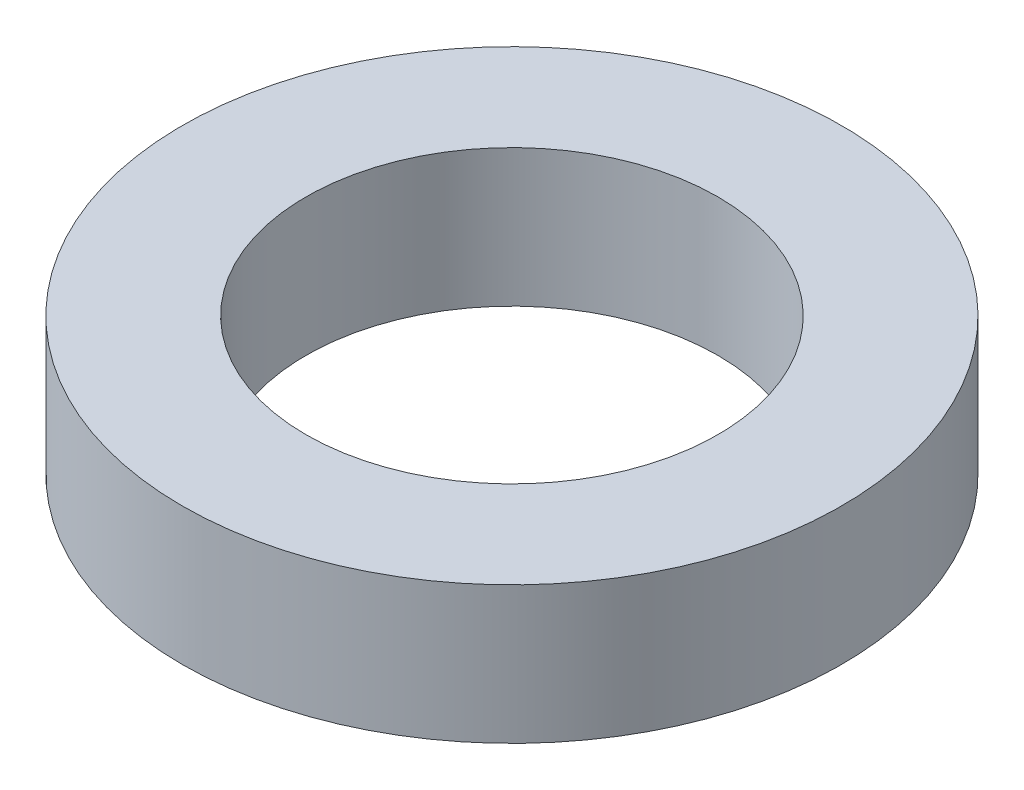
from build123d import *

# Parameters (mm, degrees)
SKETCH1_R           = 12.000000003
SKETCH1_R_2         = 7.499999986
BOSS_EXTRUDE1_DEPTH = 2.499999953


with BuildPart() as part:
    # Sketch1 → Boss-Extrude1 (new body, symmetric)
    with BuildSketch(Plane(origin=(0, 0, 0), x_dir=(1, 0, 0), z_dir=(0, 1, 0))):
        Circle(SKETCH1_R)
        Circle(SKETCH1_R_2, mode=Mode.SUBTRACT)
    extrude(amount=BOSS_EXTRUDE1_DEPTH, both=True)


solid = part.part
